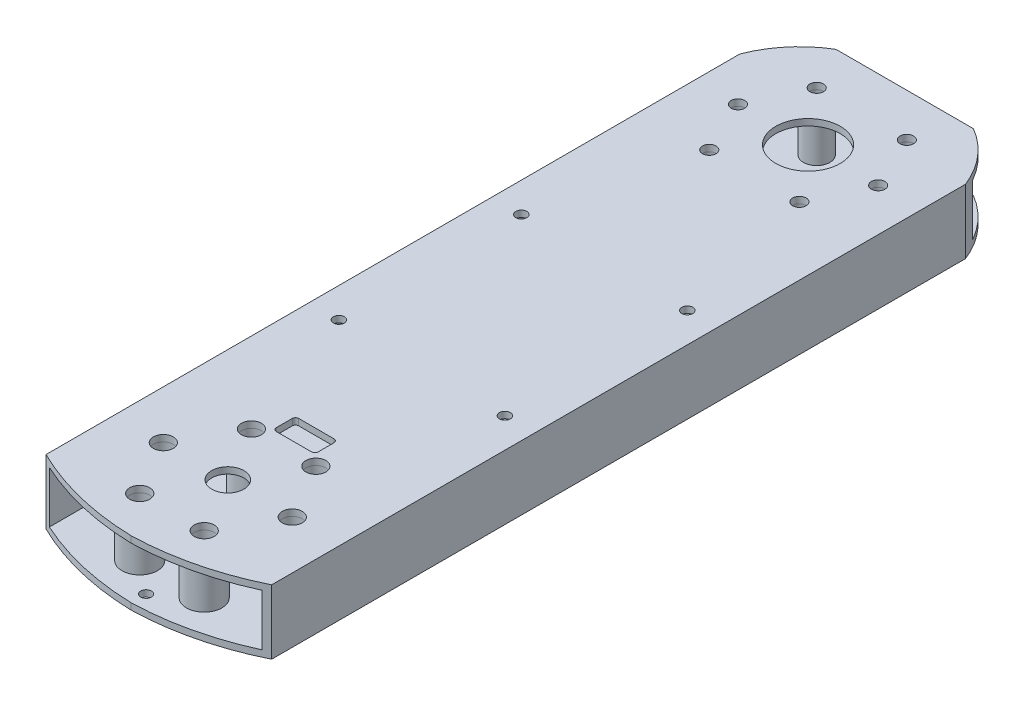
from build123d import *

# Parameters (mm, degrees)
SKETCH_1_W             = 70
SKETCH_1_H             = 20
SKETCH_1_W_2           = 66
SKETCH_1_H_2           = 16
EXTRUDE_1_DEPTH        = 240
CUT_EXTRUDE_1_REACH    = 22
SKETCH_2_R             = 10
CUT_EXTRUDE_2_REACH    = 22
SKETCH_3_R             = 5
SKETCH_4_R             = 2.1
CUT_EXTRUDE_3_DEPTH    = 21
CUT_EXTRUDE_5_REACH    = 22
CUT_EXTRUDE_8_DEPTH    = 21
SKETCH_13_R            = 3.1
CUT_EXTRUDE_10_DEPTH   = 21
CUT_EXTRUDE_11_REACH   = 22
SKETCH_14_W            = 13
SKETCH_14_H            = 7
FILLET_1_R             = 1
CUT_EXTRUDE_12_REACH   = 22
SKETCH_15_R            = 1
HOLE_WIZARD_M3_1_D     = 2.5
HOLE_WIZARD_M3_1_DEPTH = 20
SKETCH_40_R            = 1.7
CUT_EXTRUDE_21_DEPTH   = 10
SKETCH_49_R            = 4.1
SKETCH_49_R_2          = 2.2
SKETCH_49_R_3          = 5.5
SKETCH_49_R_4          = 3.2
EXTRUDE_2_DEPTH        = 16
SKETCH_50_R            = 1.7
CUT_EXTRUDE_27_DEPTH   = 2
SKETCH_51_W            = 18
SKETCH_51_H            = 65
CUT_EXTRUDE_28_DEPTH   = 2
FILLET_6_R             = 3
CUT_EXTRUDE_29_REACH   = 22
SKETCH_52_R            = 1.3
CUT_EXTRUDE_30_REACH   = 22
SKETCH_53_R            = 1.65


with BuildPart() as part:
    # 草图1 → 凸台-拉伸1 (new body)
    with BuildSketch(Plane.XY):
        Rectangle(SKETCH_1_W, SKETCH_1_H)
        Rectangle(SKETCH_1_W_2, SKETCH_1_H_2, mode=Mode.SUBTRACT)
    extrude(amount=EXTRUDE_1_DEPTH)

    # 草图2 → 切除-拉伸1 (cut, up to next)
    with BuildSketch(Plane(origin=(0, 10, 0), x_dir=(1, 0, 0), z_dir=(0, 1, 0)), mode=Mode.PRIVATE) as cut_extrude_1_sk1:
        with Locations((0, -30)):
            Circle(SKETCH_2_R)
    cut_extrude_1_tool1 = extrude(cut_extrude_1_sk1.sketch, amount=-CUT_EXTRUDE_1_REACH, mode=Mode.PRIVATE) & part.part
    add(cut_extrude_1_tool1.solids().sort_by_distance((0, 10, 30))[0], mode=Mode.SUBTRACT)

    # 草图3 → 切除-拉伸2 (cut, up to next)
    with BuildSketch(Plane(origin=(0, 10, 0), x_dir=(1, 0, 0), z_dir=(0, 1, 0)), mode=Mode.PRIVATE) as cut_extrude_2_sk1:
        with Locations((0, -210)):
            Circle(SKETCH_3_R)
    cut_extrude_2_tool1 = extrude(cut_extrude_2_sk1.sketch, amount=-CUT_EXTRUDE_2_REACH, mode=Mode.PRIVATE) & part.part
    add(cut_extrude_2_tool1.solids().sort_by_distance((0, 10, 210))[0], mode=Mode.SUBTRACT)

    # 草图4 → 切除-拉伸3 (cut, through all)
    with BuildSketch(Plane(origin=(0, 10, 0), x_dir=(1, 0, 0), z_dir=(0, 1, 0))):
        with Locations((-13.980630511, -13.338533362)):
            Circle(SKETCH_4_R)
        with Locations((-21.75, -30)):
            Circle(SKETCH_4_R)
        with Locations((13.980630511, -13.338533362)):
            Circle(SKETCH_4_R)
        with Locations((21.75, -30)):
            Circle(SKETCH_4_R)
        with Locations((13.980630511, -46.661466638)):
            Circle(SKETCH_4_R)
        with Locations((-13.980630511, -46.661466638)):
            Circle(SKETCH_4_R)
    extrude(amount=-CUT_EXTRUDE_3_DEPTH, mode=Mode.SUBTRACT)

    # 草图7 → 切除-拉伸5 (cut, up to next)
    with BuildSketch(Plane.XZ.offset(10), mode=Mode.PRIVATE) as cut_extrude_5_sk1:
        with BuildLine():
            Line((-35, 16.180278489), (-35, 0))
            Line((-35, 0), (-21.308191912, 0))
            ThreePointArc((-21.308191912, 0), (-29.522957546, 6.931803792), (-35, 16.180278489))
        make_face()
    cut_extrude_5_tool1 = extrude(cut_extrude_5_sk1.sketch, amount=-CUT_EXTRUDE_5_REACH, mode=Mode.PRIVATE) & part.part
    add(cut_extrude_5_tool1.solids().sort_by_distance((-30.953915, -10, 4.726426))[0], mode=Mode.SUBTRACT)
    # 草图7 → 切除-拉伸5 (cut, up to next)
    with BuildSketch(Plane.XZ.offset(10), mode=Mode.PRIVATE) as cut_extrude_5_sk2:
        with BuildLine():
            Line((35, 16.180278489), (35, 0))
            Line((35, 0), (21.308191912, 0))
            ThreePointArc((21.308191912, 0), (29.522957546, 6.931803792), (35, 16.180278489))
        make_face()
    cut_extrude_5_tool2 = extrude(cut_extrude_5_sk2.sketch, amount=-CUT_EXTRUDE_5_REACH, mode=Mode.PRIVATE) & part.part
    add(cut_extrude_5_tool2.solids().sort_by_distance((30.953915, -10, 4.726426))[0], mode=Mode.SUBTRACT)

    # 草图10 → 切除-拉伸8 (cut, through all)
    with BuildSketch(Plane(origin=(0, 10, 0), x_dir=(1, 0, 0), z_dir=(0, 1, 0))):
        with BuildLine():
            ThreePointArc((0, -240), (-17.966962187, -237.598213103), (-35, -231.396928288))
            Line((-35, -231.396928288), (-35, -240))
            Line((-35, -240), (0, -240))
        make_face()
        with BuildLine():
            ThreePointArc((35, -231.396928288), (17.966962187, -237.598213103), (0, -240))
            Line((0, -240), (35, -240))
            Line((35, -240), (35, -231.396928288))
        make_face()
    extrude(amount=-CUT_EXTRUDE_8_DEPTH, mode=Mode.SUBTRACT)

    # 草图13 → 切除-拉伸10 (cut, through all)
    with BuildSketch(Plane(origin=(0, 10, 0), x_dir=(1, 0, 0), z_dir=(0, 1, 0))):
        with Locations((-20, -210)):
            Circle(SKETCH_13_R)
        with Locations((-10, -192.679491924)):
            Circle(SKETCH_13_R)
        with Locations((10, -192.679491924)):
            Circle(SKETCH_13_R)
        with Locations((20, -210)):
            Circle(SKETCH_13_R)
        with Locations((10, -227.320508076)):
            Circle(SKETCH_13_R)
        with Locations((-10, -227.320508076)):
            Circle(SKETCH_13_R)
    extrude(amount=-CUT_EXTRUDE_10_DEPTH, mode=Mode.SUBTRACT)

    # 草图14 → 切除-拉伸11 (cut, up to next)
    with BuildSketch(Plane(origin=(0, 10, 0), x_dir=(1, 0, 0), z_dir=(0, 1, 0)), mode=Mode.PRIVATE) as cut_extrude_11_sk1:
        with Locations((0, -186)):
            Rectangle(SKETCH_14_W, SKETCH_14_H)
    cut_extrude_11_tool1 = extrude(cut_extrude_11_sk1.sketch, amount=-CUT_EXTRUDE_11_REACH, mode=Mode.PRIVATE) & part.part
    add(cut_extrude_11_tool1.solids().sort_by_distance((0, 10, 186))[0], mode=Mode.SUBTRACT)

    # 圆角1
    fillet_1_edges = [part.edges().sort_by_distance(p)[0] for p in [
        (-6.5, 9, 189.5),
        (-6.5, 9, 182.5),
        (6.5, 9, 182.5),
        (6.5, 9, 189.5),
    ]]
    fillet(fillet_1_edges, radius=FILLET_1_R)

    # 草图15 → 切除-拉伸12 (cut, up to next)
    with BuildSketch(Plane.XZ.offset(10), mode=Mode.PRIVATE) as cut_extrude_12_sk1:
        with Locations((0, 30)):
            Circle(SKETCH_15_R)
    cut_extrude_12_tool1 = extrude(cut_extrude_12_sk1.sketch, amount=-CUT_EXTRUDE_12_REACH, mode=Mode.PRIVATE) & part.part
    add(cut_extrude_12_tool1.solids().sort_by_distance((0, -10, 30))[0], mode=Mode.SUBTRACT)

    # M3 螺纹孔1
    with Locations(Plane(origin=(0, -10, 30), x_dir=(0, 0, -1), z_dir=(0, -1, 0))):
        with Locations((0, 0), (-180, 0)):
            Hole(HOLE_WIZARD_M3_1_D / 2, depth=HOLE_WIZARD_M3_1_DEPTH)

    # 草图40 → 切除-拉伸21 (cut)
    with BuildSketch(Plane.XZ.offset(10)):
        with Locations((-4, 20)):
            Circle(SKETCH_40_R)
        with Locations((4, 20)):
            Circle(SKETCH_40_R)
    extrude(amount=-CUT_EXTRUDE_21_DEPTH, mode=Mode.SUBTRACT)

    # 草图49 → 凸台-拉伸2 (add)
    with BuildSketch(Plane.XZ.offset(-8)):
        with Locations((-13.980630511, 46.661466638)):
            Circle(SKETCH_49_R)
        with Locations((-13.980630511, 46.661466638)):
            Circle(SKETCH_49_R_2, mode=Mode.SUBTRACT)
        with Locations((-21.75, 30)):
            Circle(SKETCH_49_R)
        with Locations((-21.75, 30)):
            Circle(SKETCH_49_R_2, mode=Mode.SUBTRACT)
        with Locations((-13.980630511, 13.338533362)):
            Circle(SKETCH_49_R)
        with Locations((-13.980630511, 13.338533362)):
            Circle(SKETCH_49_R_2, mode=Mode.SUBTRACT)
        with Locations((13.980630511, 13.338533362)):
            Circle(SKETCH_49_R)
        with Locations((13.980630511, 13.338533362)):
            Circle(SKETCH_49_R_2, mode=Mode.SUBTRACT)
        with Locations((21.75, 30)):
            Circle(SKETCH_49_R)
        with Locations((21.75, 30)):
            Circle(SKETCH_49_R_2, mode=Mode.SUBTRACT)
        with Locations((13.980630511, 46.661466638)):
            Circle(SKETCH_49_R)
        with Locations((13.980630511, 46.661466638)):
            Circle(SKETCH_49_R_2, mode=Mode.SUBTRACT)
        with Locations((-10, 227.320508076)):
            Circle(SKETCH_49_R_3)
        with Locations((-10, 227.320508076)):
            Circle(SKETCH_49_R_4, mode=Mode.SUBTRACT)
        with Locations((10, 227.320508076)):
            Circle(SKETCH_49_R_3)
        with Locations((10, 227.320508076)):
            Circle(SKETCH_49_R_4, mode=Mode.SUBTRACT)
        with Locations((20, 210)):
            Circle(SKETCH_49_R_3)
        with Locations((20, 210)):
            Circle(SKETCH_49_R_4, mode=Mode.SUBTRACT)
        with Locations((10, 192.679491924)):
            Circle(SKETCH_49_R_3)
        with Locations((10, 192.679491924)):
            Circle(SKETCH_49_R_4, mode=Mode.SUBTRACT)
        with Locations((-10, 192.679491924)):
            Circle(SKETCH_49_R_3)
        with Locations((-10, 192.679491924)):
            Circle(SKETCH_49_R_4, mode=Mode.SUBTRACT)
        with Locations((-20, 210)):
            Circle(SKETCH_49_R_3)
        with Locations((-20, 210)):
            Circle(SKETCH_49_R_4, mode=Mode.SUBTRACT)
    extrude(amount=EXTRUDE_2_DEPTH)

    # 草图50 → 切除-拉伸27 (cut)
    with BuildSketch(Plane(origin=(0, 10, 0), x_dir=(1, 0, 0), z_dir=(0, 1, 0))):
        with Locations((-25.75, -93.2)):
            Circle(SKETCH_50_R)
        with Locations((25.75, -93.2)):
            Circle(SKETCH_50_R)
        with Locations((-25.75, -149.8)):
            Circle(SKETCH_50_R)
        with Locations((25.75, -149.8)):
            Circle(SKETCH_50_R)
    extrude(amount=-CUT_EXTRUDE_27_DEPTH, mode=Mode.SUBTRACT)

    # 草图51 → 切除-拉伸28 (cut)
    with BuildSketch(Plane.XZ.offset(10)):
        with Locations((-20, 120.5)):
            Rectangle(SKETCH_51_W, SKETCH_51_H)
    extrude(amount=-CUT_EXTRUDE_28_DEPTH, mode=Mode.SUBTRACT)

    # 圆角6
    fillet_6_edges = [part.edges().sort_by_distance(p)[0] for p in [
        (-11, -9, 153),
        (-11, -9, 88),
        (-29, -9, 88),
        (-29, -9, 153),
    ]]
    fillet(fillet_6_edges, radius=FILLET_6_R)

    # 草图52 → 切除-拉伸29 (cut, up to next)
    with BuildSketch(Plane.XZ.offset(10), mode=Mode.PRIVATE) as cut_extrude_29_sk1:
        with Locations((-24, 168.788603388)):
            Circle(SKETCH_52_R)
    cut_extrude_29_tool1 = extrude(cut_extrude_29_sk1.sketch, amount=-CUT_EXTRUDE_29_REACH, mode=Mode.PRIVATE) & part.part
    add(cut_extrude_29_tool1.solids().sort_by_distance((-24, -10, 168.788603))[0], mode=Mode.SUBTRACT)
    # 草图52 → 切除-拉伸29 (cut, up to next)
    with BuildSketch(Plane.XZ.offset(10), mode=Mode.PRIVATE) as cut_extrude_29_sk2:
        with Locations((-24, 78.788603388)):
            Circle(SKETCH_52_R)
    cut_extrude_29_tool2 = extrude(cut_extrude_29_sk2.sketch, amount=-CUT_EXTRUDE_29_REACH, mode=Mode.PRIVATE) & part.part
    add(cut_extrude_29_tool2.solids().sort_by_distance((-24, -10, 78.788603))[0], mode=Mode.SUBTRACT)
    # 草图52 → 切除-拉伸29 (cut, up to next)
    with BuildSketch(Plane.XZ.offset(10), mode=Mode.PRIVATE) as cut_extrude_29_sk3:
        with Locations((24, 78.788603388)):
            Circle(SKETCH_52_R)
    cut_extrude_29_tool3 = extrude(cut_extrude_29_sk3.sketch, amount=-CUT_EXTRUDE_29_REACH, mode=Mode.PRIVATE) & part.part
    add(cut_extrude_29_tool3.solids().sort_by_distance((24, -10, 78.788603))[0], mode=Mode.SUBTRACT)
    # 草图52 → 切除-拉伸29 (cut, up to next)
    with BuildSketch(Plane.XZ.offset(10), mode=Mode.PRIVATE) as cut_extrude_29_sk4:
        with Locations((24, 168.788603388)):
            Circle(SKETCH_52_R)
    cut_extrude_29_tool4 = extrude(cut_extrude_29_sk4.sketch, amount=-CUT_EXTRUDE_29_REACH, mode=Mode.PRIVATE) & part.part
    add(cut_extrude_29_tool4.solids().sort_by_distance((24, -10, 168.788603))[0], mode=Mode.SUBTRACT)

    # 草图53 → 切除-拉伸30 (cut, up to next)
    with BuildSketch(Plane.XZ.offset(10), mode=Mode.PRIVATE) as cut_extrude_30_sk1:
        with Locations((0, 235.348491094)):
            Circle(SKETCH_53_R)
    cut_extrude_30_tool1 = extrude(cut_extrude_30_sk1.sketch, amount=-CUT_EXTRUDE_30_REACH, mode=Mode.PRIVATE) & part.part
    add(cut_extrude_30_tool1.solids().sort_by_distance((0, -10, 235.348491))[0], mode=Mode.SUBTRACT)


solid = part.part
